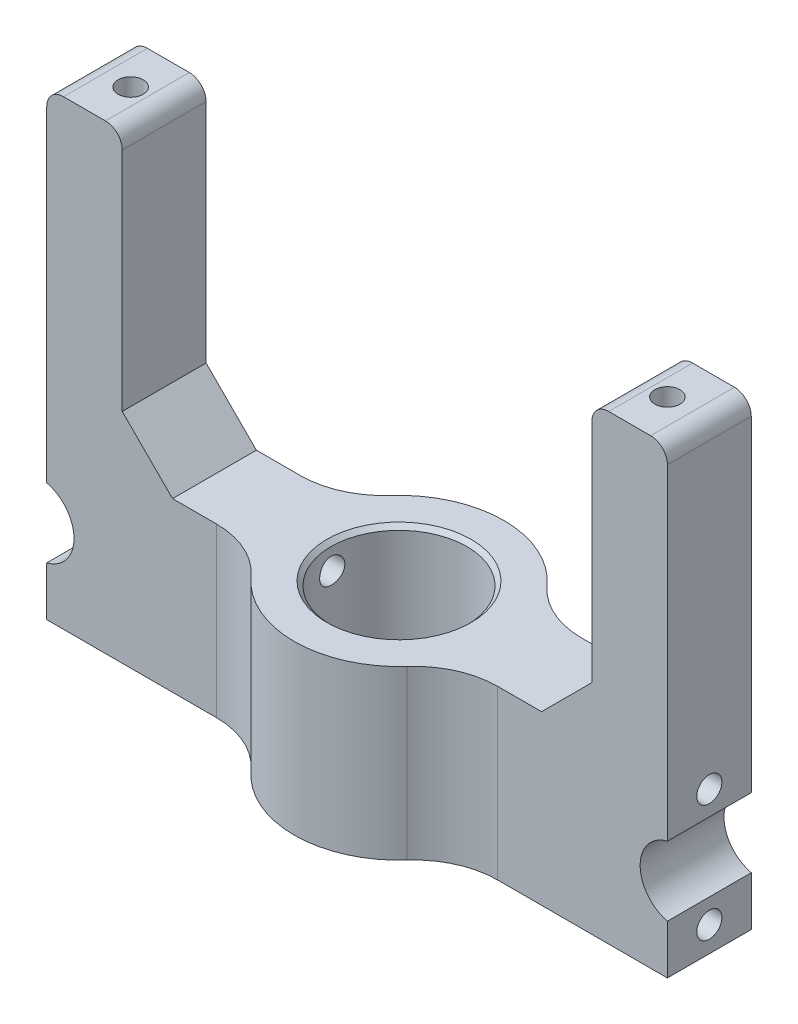
from build123d import *

# Parameters (mm, degrees)
SKETCH1_W                = 88
SKETCH1_H                = 10
BOSS_EXTRUDE1_DEPTH      = 20
SKETCH2_R                = 4.25
CUT_EXTRUDE1_DEPTH       = 11
SKETCH7_R                = 12.5
BOSS_EXTRUDE2_DEPTH      = 20
SKETCH4_R                = 8.1
CUT_EXTRUDE3_DEPTH       = 21
FILLET2_R                = 10
SKETCH9_W                = 7
SKETCH9_H                = 20
CUT_EXTRUDE6_DEPTH       = 18.5
SKETCH10_W               = 9
SKETCH10_H               = 10
BOSS_EXTRUDE3_DEPTH      = 35
SKETCH11_R               = 1.5
CUT_EXTRUDE7_DEPTH       = 20
CHAMFER1_SIZE            = 6
FILLET3_R                = 2
CHAMFER1_OF_MIRROR1_SIZE = 6
FILLET3_OF_MIRROR1_R     = 2
CHAMFER2_SIZE            = 0.5
SKETCH12_R               = 1.5
CUT_EXTRUDE8_DEPTH       = 75


with BuildPart() as part:
    # Sketch1 → Boss-Extrude1 (new body)
    with BuildSketch(Plane(origin=(0, 0, 0), x_dir=(1, 0, 0), z_dir=(0, 1, 0))):
        Rectangle(SKETCH1_W, SKETCH1_H)
    extrude(amount=BOSS_EXTRUDE1_DEPTH)

    # Sketch2 → Cut-Extrude1 (cut, through all)
    with BuildSketch(Plane.XY.offset(5)):
        with Locations((-38, 10)):
            Circle(SKETCH2_R)
        with Locations((38, 10)):
            Circle(SKETCH2_R)
    extrude(amount=-CUT_EXTRUDE1_DEPTH, mode=Mode.SUBTRACT)

    # Sketch7 → Boss-Extrude2 (add)
    with BuildSketch(Plane(origin=(0, 20, 0), x_dir=(1, 0, 0), z_dir=(0, 1, 0))):
        Circle(SKETCH7_R)
    extrude(amount=-BOSS_EXTRUDE2_DEPTH)

    # Sketch4 → Cut-Extrude3 (cut, through all)
    with BuildSketch(Plane(origin=(0, 20, 0), x_dir=(1, 0, 0), z_dir=(0, 1, 0))):
        Circle(SKETCH4_R)
    extrude(amount=-CUT_EXTRUDE3_DEPTH, mode=Mode.SUBTRACT)

    # Fillet2
    fillet2_edges = [part.edges().sort_by_distance(p)[0] for p in [
        (11.456439237, 10, -5),
        (11.456439237, 10, 5),
        (-11.456439237, 10, -5),
        (-11.456439237, 10, 5),
    ]]
    fillet(fillet2_edges, radius=FILLET2_R)

    # Sketch9 → Cut-Extrude6 (cut, through all)
    with BuildSketch(Plane.XY.offset(5)):
        with Locations((-40.5, 10)):
            Rectangle(SKETCH9_W, SKETCH9_H)
        with Locations((40.5, 10)):
            Rectangle(SKETCH9_W, SKETCH9_H)
    extrude(amount=-CUT_EXTRUDE6_DEPTH, mode=Mode.SUBTRACT)

    # Sketch10 → Boss-Extrude3 (add)
    with BuildSketch(Plane(origin=(0, 20, 0), x_dir=(1, 0, 0), z_dir=(0, 1, 0))):
        with Locations((-32.5, 0)):
            Rectangle(SKETCH10_W, SKETCH10_H)
    boss_extrude3 = extrude(amount=BOSS_EXTRUDE3_DEPTH)

    # Sketch11 → Cut-Extrude7 (cut)
    with BuildSketch(Plane(origin=(0, 55, 0), x_dir=(1, 0, 0), z_dir=(0, 1, 0))):
        with Locations((-32, 0)):
            Circle(SKETCH11_R)
    cut_extrude7 = extrude(amount=-CUT_EXTRUDE7_DEPTH, mode=Mode.SUBTRACT)

    # Chamfer1
    chamfer1_edges = [part.edges().sort_by_distance(p)[0] for p in [
        (-28, 20, 0),
    ]]
    chamfer(chamfer1_edges, length=CHAMFER1_SIZE)

    # Fillet3
    fillet3_edges = [part.edges().sort_by_distance(p)[0] for p in [
        (-37, 55, 0),
        (-28, 55, 0),
    ]]
    fillet(fillet3_edges, radius=FILLET3_R)

    # Mirror1: Boss-Extrude3, Cut-Extrude7 across plane
    add(boss_extrude3.mirror(Plane(origin=(0, 0, 0), x_dir=(0, 0, 1), z_dir=(1, 0, 0))))
    add(cut_extrude7.mirror(Plane(origin=(0, 0, 0), x_dir=(0, 0, 1), z_dir=(1, 0, 0))), mode=Mode.SUBTRACT)

    # Chamfer1 of Mirror1
    chamfer1_of_mirror1_edges = [part.edges().sort_by_distance(p)[0] for p in [
        (28, 20, 0),
    ]]
    chamfer(chamfer1_of_mirror1_edges, length=CHAMFER1_OF_MIRROR1_SIZE)

    # Fillet3 of Mirror1
    fillet3_of_mirror1_edges = [part.edges().sort_by_distance(p)[0] for p in [
        (37, 55, 0),
        (28, 55, 0),
    ]]
    fillet(fillet3_of_mirror1_edges, radius=FILLET3_OF_MIRROR1_R)

    # Chamfer2
    chamfer2_edges = [part.edges().sort_by_distance(p)[0] for p in [
        (-8.1, 0, 0),
        (-8.1, 20, 0),
    ]]
    chamfer(chamfer2_edges, length=CHAMFER2_SIZE)

    # Sketch12 → Cut-Extrude8 (cut, through all)
    with BuildSketch(Plane.ZY.offset(37)):
        with Locations((0, 3)):
            Circle(SKETCH12_R)
        with Locations((0, 17)):
            Circle(SKETCH12_R)
    extrude(amount=-CUT_EXTRUDE8_DEPTH, mode=Mode.SUBTRACT)


solid = part.part
